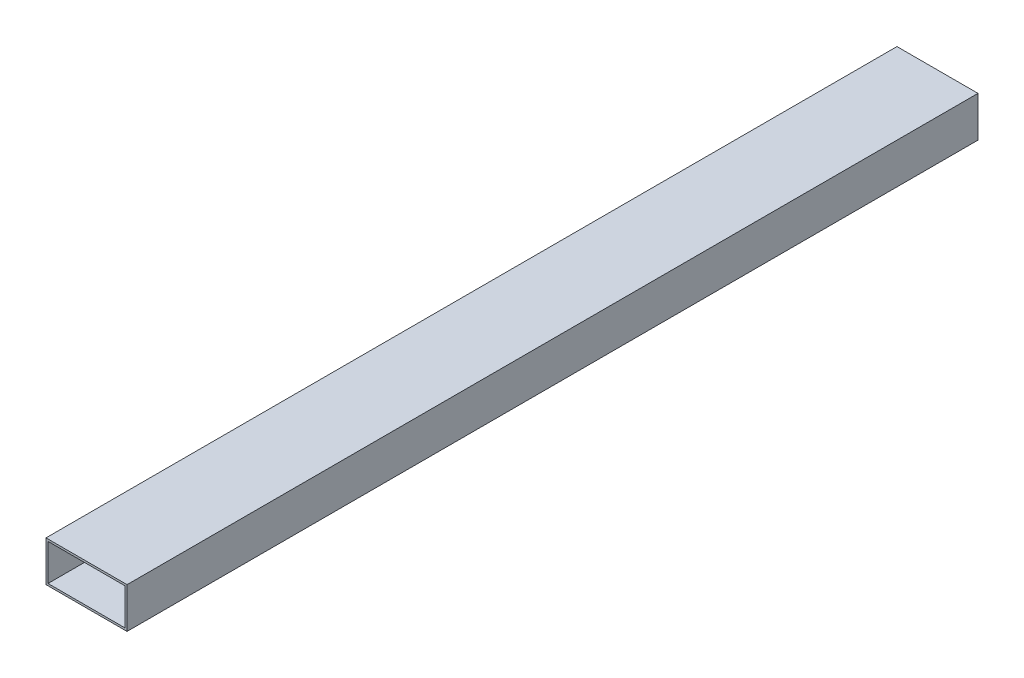
from build123d import *

# Parameters (mm, degrees)
SKETCH1_W           = 40
SKETCH1_H           = 20
BOSS_EXTRUDE1_DEPTH = 420
SKETCH2_W           = 38
SKETCH2_H           = 18
CUT_EXTRUDE1_DEPTH  = 421


with BuildPart() as part:
    # Sketch1 → Boss-Extrude1 (new body)
    with BuildSketch(Plane.XY):
        Rectangle(SKETCH1_W, SKETCH1_H)
    extrude(amount=BOSS_EXTRUDE1_DEPTH)

    # Sketch2 → Cut-Extrude1 (cut, through all)
    with BuildSketch(Plane.XY.offset(420)):
        Rectangle(SKETCH2_W, SKETCH2_H)
    extrude(amount=-CUT_EXTRUDE1_DEPTH, mode=Mode.SUBTRACT)


solid = part.part
